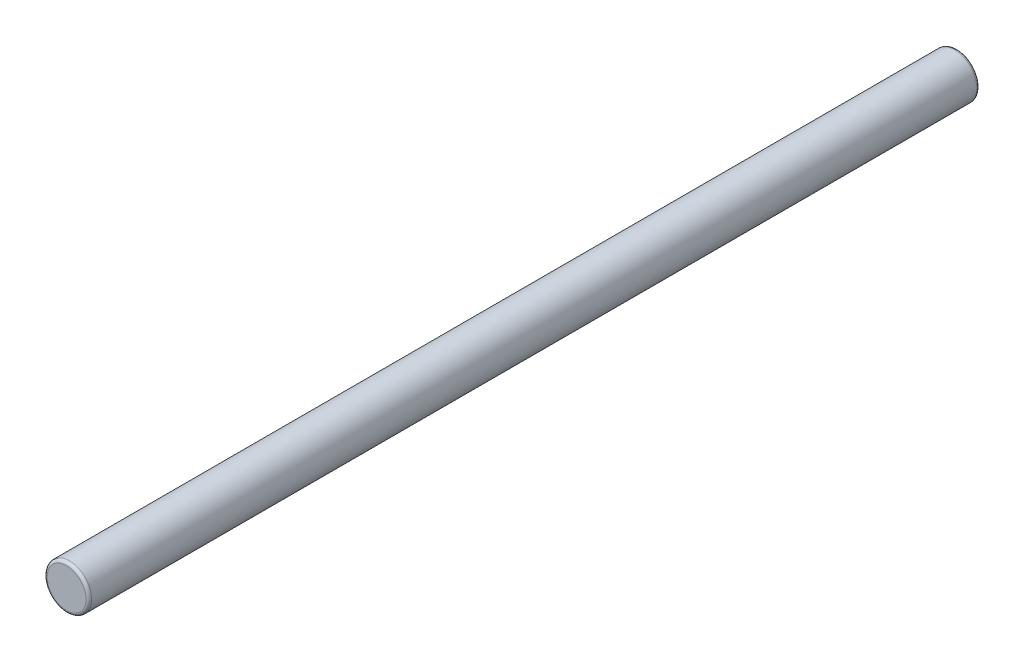
from build123d import *

# Parameters (mm, degrees)
SKETCH1_R           = 1
BOSS_EXTRUDE1_DEPTH = 20
FILLET1_R           = 0.127


with BuildPart() as part:
    # Sketch1 → Boss-Extrude1 (new body, symmetric)
    with BuildSketch(Plane.XY):
        Circle(SKETCH1_R)
    extrude(amount=BOSS_EXTRUDE1_DEPTH, both=True)

    # Fillet1
    fillet1_edges = [part.edges().sort_by_distance(p)[0] for p in [
        (-1, 0, -20),
        (-1, 0, 20),
    ]]
    fillet(fillet1_edges, radius=FILLET1_R)


solid = part.part
